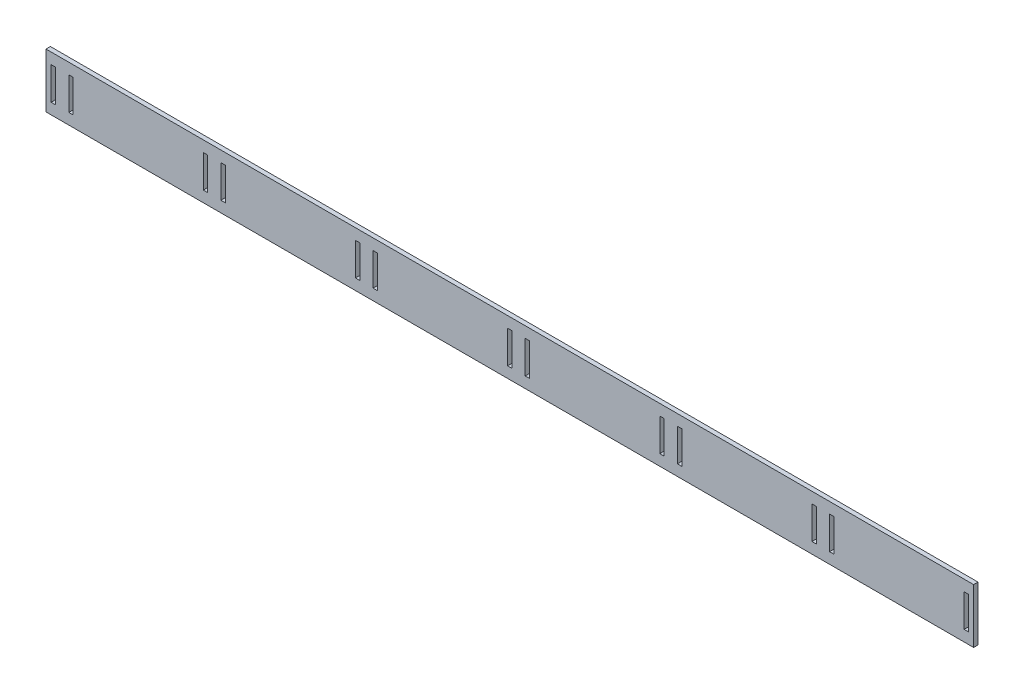
from build123d import *

# Parameters (mm, degrees)
SKETCH2_W           = 424
SKETCH2_H           = 24.9
SKETCH2_W_2         = 2
SKETCH2_H_2         = 14.9
BOSS_EXTRUDE1_DEPTH = 2


with BuildPart() as part:
    # Sketch2 → Boss-Extrude1 (new body)
    with BuildSketch(Plane.XY):
        with Locations((212, -12.45)):
            Rectangle(SKETCH2_W, SKETCH2_H)
        with Locations((3.35, -12.45)):
            Rectangle(SKETCH2_W_2, SKETCH2_H_2, mode=Mode.SUBTRACT)
        with Locations((11.4, -12.45)):
            Rectangle(SKETCH2_W_2, SKETCH2_H_2, mode=Mode.SUBTRACT)
        with Locations((72.9, -12.45)):
            Rectangle(SKETCH2_W_2, SKETCH2_H_2, mode=Mode.SUBTRACT)
        with Locations((80.95, -12.45)):
            Rectangle(SKETCH2_W_2, SKETCH2_H_2, mode=Mode.SUBTRACT)
        with Locations((142.45, -12.45)):
            Rectangle(SKETCH2_W_2, SKETCH2_H_2, mode=Mode.SUBTRACT)
        with Locations((150.5, -12.45)):
            Rectangle(SKETCH2_W_2, SKETCH2_H_2, mode=Mode.SUBTRACT)
        with Locations((212, -12.45)):
            Rectangle(SKETCH2_W_2, SKETCH2_H_2, mode=Mode.SUBTRACT)
        with Locations((220.05, -12.45)):
            Rectangle(SKETCH2_W_2, SKETCH2_H_2, mode=Mode.SUBTRACT)
        with Locations((281.55, -12.45)):
            Rectangle(SKETCH2_W_2, SKETCH2_H_2, mode=Mode.SUBTRACT)
        with Locations((289.6, -12.45)):
            Rectangle(SKETCH2_W_2, SKETCH2_H_2, mode=Mode.SUBTRACT)
        with Locations((351.1, -12.45)):
            Rectangle(SKETCH2_W_2, SKETCH2_H_2, mode=Mode.SUBTRACT)
        with Locations((359.15, -12.45)):
            Rectangle(SKETCH2_W_2, SKETCH2_H_2, mode=Mode.SUBTRACT)
        with Locations((420.65, -12.45)):
            Rectangle(SKETCH2_W_2, SKETCH2_H_2, mode=Mode.SUBTRACT)
    extrude(amount=BOSS_EXTRUDE1_DEPTH)


solid = part.part
